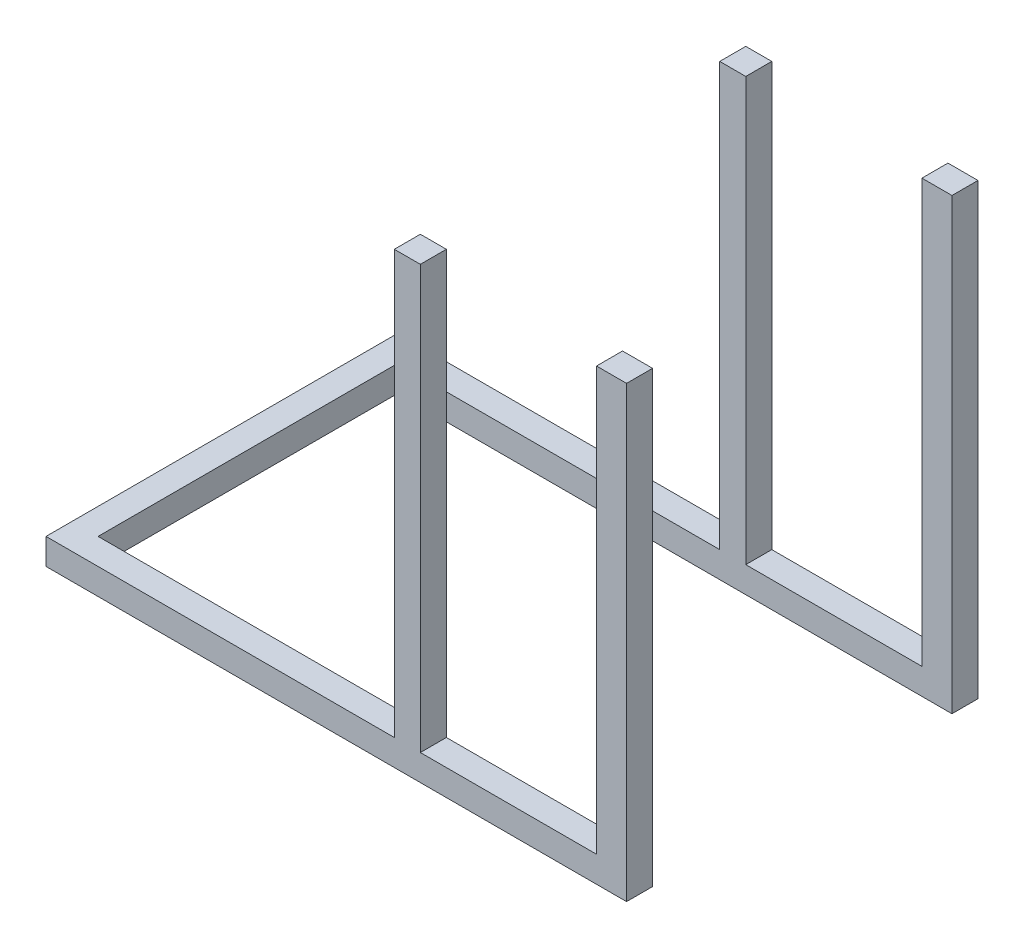
from build123d import *

# Parameters (mm, degrees)
SALIENTE_EXTRUIR1_DEPTH = 58
CROQUIS3_W              = 58
CROQUIS3_H              = 58
CROQUIS3_W_2            = 66.947748122
SALIENTE_EXTRUIR2_DEPTH = 1000


with BuildPart() as part:
    # Croquis2 → Saliente-Extruir1 (new body)
    with BuildSketch(Plane(origin=(0, 0, 0), x_dir=(1, 0, 0), z_dir=(0, 1, 0))):
        Polygon((858.4, -333.5), (858.4, -391.5), (-435, -391.5), (-435, 391.5), (858.4, 391.5), (858.4, 333.5), (-377, 333.5), (-377, -333.5), align=None)
    extrude(amount=SALIENTE_EXTRUIR1_DEPTH)

    # Croquis3 → Saliente-Extruir2 (add)
    with BuildSketch(Plane(origin=(0, 0, 0), x_dir=(1, 0, 0), z_dir=(0, 1, 0))):
        with Locations((370, 362.5)):
            Rectangle(CROQUIS3_W, CROQUIS3_H)
        with Locations((824.926125939, 362.5)):
            Rectangle(CROQUIS3_W_2, CROQUIS3_H)
        with Locations((824.926125939, -362.5)):
            Rectangle(CROQUIS3_W_2, CROQUIS3_H)
        with Locations((370, -362.5)):
            Rectangle(CROQUIS3_W, CROQUIS3_H)
    extrude(amount=SALIENTE_EXTRUIR2_DEPTH)


solid = part.part
